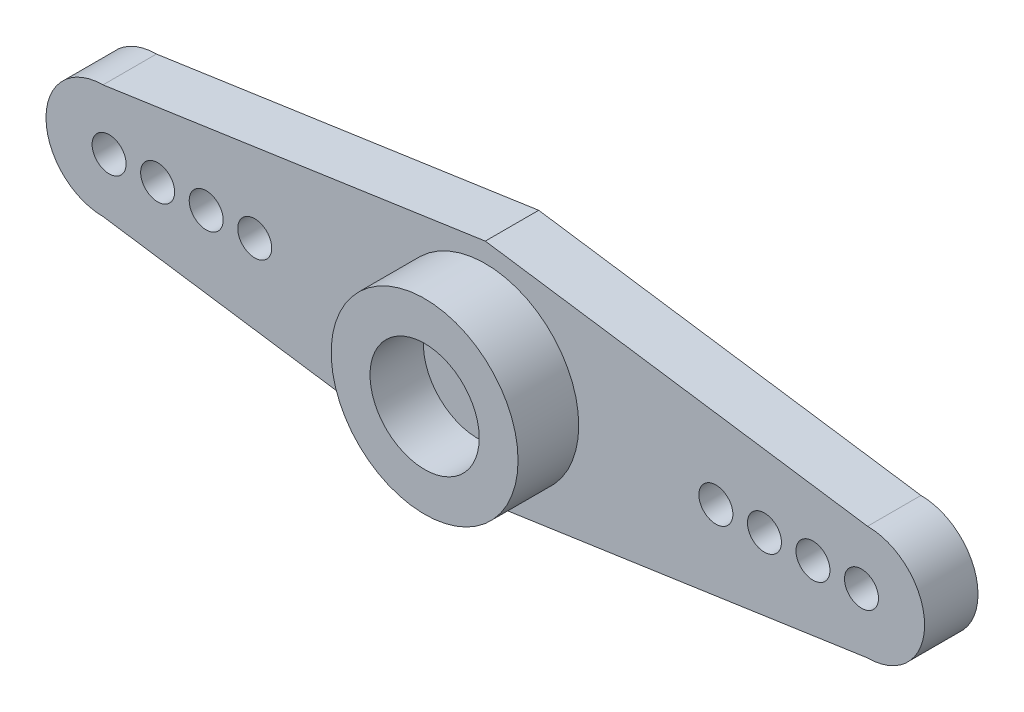
from build123d import *

# Parameters (mm, degrees)
SKETCH1_W         = 45.974
SKETCH1_H         = 11.811
EXTRUDE1_DEPTH    = 5.969
SKETCH2_OUTSIDE_W = 57.542
SKETCH2_OUTSIDE_H = 23.379
SKETCH2_OUTSIDE_R = 4.8895
EXTRUDE2_DEPTH    = 3.175
SKETCH3_R         = 2.8575
EXTRUDE3_DEPTH    = 2.794
LPATTERN1_COUNT   = 4
LPATTERN1_PITCH   = 2.54
EXTRUDE4_DEPTH    = 6.969


with BuildPart() as part:
    # Sketch1 → Extrude1 (new body)
    with BuildSketch(Plane.XY):
        Rectangle(SKETCH1_W, SKETCH1_H)
    extrude(amount=EXTRUDE1_DEPTH)

    # Sketch2 outside → Extrude2 (cut)
    with BuildSketch(Plane.XY.offset(5.969)):
        with Locations((0, -0.0005)):
            Rectangle(SKETCH2_OUTSIDE_W, SKETCH2_OUTSIDE_H)
        Circle(SKETCH2_OUTSIDE_R, mode=Mode.SUBTRACT)
    extrude(amount=-EXTRUDE2_DEPTH, mode=Mode.SUBTRACT)

    # Sketch3 → Extrude3 (cut)
    with BuildSketch(Plane.XY.offset(5.969)):
        Circle(SKETCH3_R)
    extrude(amount=-EXTRUDE3_DEPTH, mode=Mode.SUBTRACT)

    # Sketch5 → #50 (0.07) Diameter Hole1 (revolve, cut)
    with BuildSketch(Plane.YZ.offset(12.065)):
        Polygon((0, 0), (0, 5.61416509), (0.889, 5.08), (0.889, 0), align=None)
    f_50_0_07_diameter_hole1 = revolve(axis=Axis((12.065, 0, -6.35), (0, 0, 1)), mode=Mode.SUBTRACT)

    # LPattern1: #50 (0.07) Diameter Hole1 ×4
    with Locations(*[(i * LPATTERN1_PITCH, 0, 0) for i in range(1, LPATTERN1_COUNT)]):
        add(f_50_0_07_diameter_hole1, mode=Mode.SUBTRACT)

    # Mirror1: #50 (0.07) Diameter Hole1 across plane
    add(f_50_0_07_diameter_hole1.mirror(Plane(origin=(0, 0, 0), x_dir=(0, 0, 1), z_dir=(1, 0, 0))), mode=Mode.SUBTRACT)

    # Mirror1 copy 1 sketch → Mirror1 copy 1 (revolve, cut)
    with BuildSketch(Plane(origin=(-14.605, 0, 0), x_dir=(0, 1, 0), z_dir=(-1, 0, 0))):
        Polygon((0, 0), (0, -5.61416509), (0.889, -5.08), (0.889, 0), align=None)
    revolve(axis=Axis((-14.605, 0, -6.35), (0, 0, -1)), mode=Mode.SUBTRACT)

    # Mirror1 copy 2 sketch → Mirror1 copy 2 (revolve, cut)
    with BuildSketch(Plane(origin=(-17.145, 0, 0), x_dir=(0, 1, 0), z_dir=(-1, 0, 0))):
        Polygon((0, 0), (0, -5.61416509), (0.889, -5.08), (0.889, 0), align=None)
    revolve(axis=Axis((-17.145, 0, -6.35), (0, 0, -1)), mode=Mode.SUBTRACT)

    # Mirror1 copy 3 sketch → Mirror1 copy 3 (revolve, cut)
    with BuildSketch(Plane(origin=(-19.685, 0, 0), x_dir=(0, 1, 0), z_dir=(-1, 0, 0))):
        Polygon((0, 0), (0, -5.61416509), (0.889, -5.08), (0.889, 0), align=None)
    revolve(axis=Axis((-19.685, 0, -6.35), (0, 0, -1)), mode=Mode.SUBTRACT)

    # Sketch6 → Extrude4 (cut, through all)
    with BuildSketch(Plane(origin=(0, 0, 0), x_dir=(-1, 0, 0), z_dir=(0, 0, -1))):
        with BuildLine():
            Line((-61.04017999, 14.819304062), (0, 5.9055))
            Line((0, 5.9055), (20.0025, 2.9845))
            ThreePointArc((20.0025, 2.9845), (22.112860188, 2.110360188), (22.987, 0))
            ThreePointArc((22.987, 0), (22.112860188, -2.110360188), (20.0025, -2.9845))
            Line((20.0025, -2.9845), (0, -5.9055))
            Line((0, -5.9055), (-61.04017999, -14.819304062))
            Line((-61.04017999, -14.819304062), (62.335011618, -14.819304062))
            Line((62.335011618, -14.819304062), (62.335011618, 14.819304062))
            Line((62.335011618, 14.819304062), (-61.04017999, 14.819304062))
        make_face()
    extrude4 = extrude(amount=-EXTRUDE4_DEPTH, mode=Mode.SUBTRACT)

    # Mirror2: Extrude4 across plane
    add(extrude4.mirror(Plane(origin=(0, 0, 0), x_dir=(0, 0, 1), z_dir=(1, 0, 0))), mode=Mode.SUBTRACT)


solid = part.part
